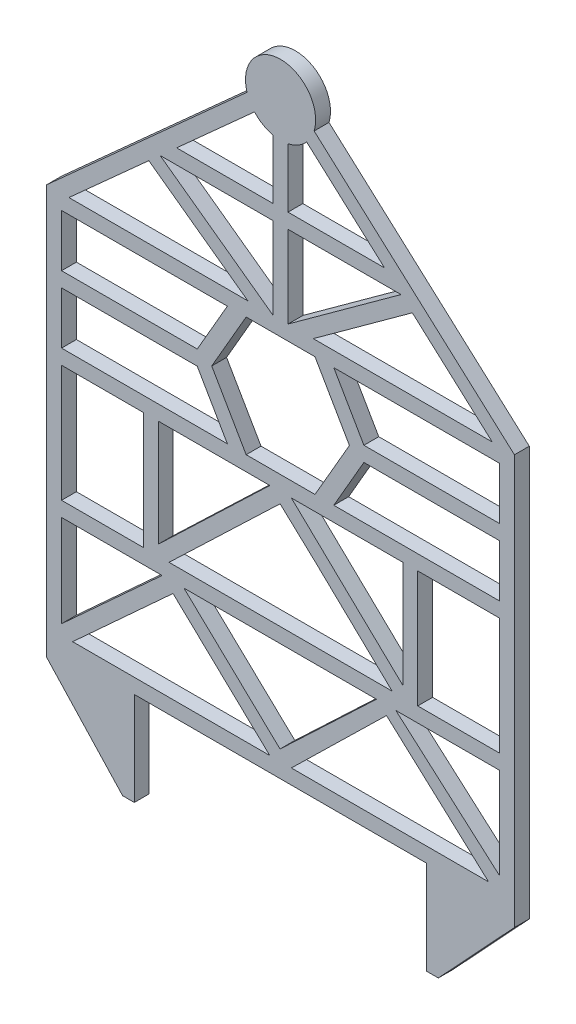
from build123d import *

# Parameters (mm, degrees)
SKETCH2_W           = 70
SKETCH2_H           = 100
BOSS_EXTRUDE3_DEPTH = 12.7


with BuildPart() as part:
    # Sketch2 → Boss-Extrude3 (new body)
    with BuildSketch(Plane.XY):
        with BuildLine():
            Line((-200, -230.044545372), (-135.055496126, -300))
            Line((-135.055496126, -300), (-125.080405008, -300))
            Line((-125.080405008, -300), (-125.080405008, -220))
            Line((-125.080405008, -220), (124.919594992, -220))
            Line((124.919594992, -220), (124.919594992, -300))
            Line((124.919594992, -300), (134.911595754, -300))
            Line((134.911595754, -300), (200, -230.044545372))
            Line((200, -230.044545372), (200, 120.049170717))
            Line((200, 120.049170717), (28.699194546, 274.177780708))
            ThreePointArc((28.699194546, 274.177780708), (0, 312.915986038), (-28.699194546, 274.177780708))
            Line((-28.699194546, 274.177780708), (-200, 120.049170717))
            Line((-200, 120.049170717), (-200, -230.044545372))
        make_face()
        Polygon((-187.3, -198.731620565), (-187.3, -120), (-101.303698117, -120), align=None, mode=Mode.SUBTRACT)
        Polygon((-177.851600054, -207.3), (-91.979918019, -128.682471814), (-9.219885484, -207.3), align=None, mode=Mode.SUBTRACT)
        Polygon((-0.473030641, -198.092257044), (-82.680114516, -120), (82.015084133, -120), align=None, mode=Mode.SUBTRACT)
        with Locations((-152.3, -57.3)):
            Rectangle(SKETCH2_W, SKETCH2_H, mode=Mode.SUBTRACT)
        Polygon((-71.265160823, 50.024585359), (-45.501144454, 5.4), (-187.3, 5.4), (-187.3, 50.024585359), align=None, mode=Mode.SUBTRACT)
        Polygon((-104.6, -7.3), (-9.189123593, -7.3), (-104.6, -98.514987005), align=None, mode=Mode.SUBTRACT)
        Polygon((177.8939034, -207.3), (9.189123593, -207.3), (90.58572411, -127.795746586), (161.581783291, -192.372871222), align=None, mode=Mode.SUBTRACT)
        Polygon((187.3, -198.092257044), (98.567023769, -120), (187.3, -120), align=None, mode=Mode.SUBTRACT)
        Polygon((-95.410876407, -107.3), (-0.412987416, -16.479838441), (30.242078983, -44.997134394), (95.410876407, -107.3), align=None, mode=Mode.SUBTRACT)
        Polygon((9.189123593, -7.3), (104.6, -7.3), (104.6, -98.514987005), align=None, mode=Mode.SUBTRACT)
        with Locations((152.3, -57.3)):
            Rectangle(SKETCH2_W, SKETCH2_H, mode=Mode.SUBTRACT)
        Polygon((-45.501144454, 107.349170717), (-71.265160823, 62.724585359), (-187.3, 62.724585359), (-187.3, 107.349170717), align=None, mode=Mode.SUBTRACT)
        Polygon((-112.679699791, 181.531958935), (-27.970761031, 120.049170717), (-181.012575458, 120.049170717), align=None, mode=Mode.SUBTRACT)
        Polygon((-103.026071592, 190.217850935), (-6.35, 190.217850935), (-6.35, 120.049170717), align=None, mode=Mode.SUBTRACT)
        with BuildLine():
            Line((-6.35, 253.595728536), (-6.35, 202.917850935))
            Line((-6.35, 202.917850935), (-88.911104686, 202.917850935))
            Line((-88.911104686, 202.917850935), (-22.301550494, 262.85007351))
            ThreePointArc((-22.301550494, 262.85007351), (-15.054519642, 256.966777219), (-6.35, 253.595728536))
        make_face(mode=Mode.SUBTRACT)
        Polygon((29.439464567, 5.383936982), (-29.439464567, 5.383936982), (-58.878929133, 56.374585359), (-29.439464567, 107.365233736), (29.439464567, 107.365233736), (58.878929133, 56.374585359), align=None, mode=Mode.SUBTRACT)
        Polygon((187.3, 5.4), (45.501144454, 5.4), (71.265160823, 50.024585359), (187.3, 50.024585359), align=None, mode=Mode.SUBTRACT)
        Polygon((187.3, 107.349170717), (187.3, 62.724585359), (71.265160823, 62.724585359), (45.501144454, 107.349170717), align=None, mode=Mode.SUBTRACT)
        Polygon((6.35, 120.049170717), (6.35, 190.217850935), (103.026071592, 190.217850935), align=None, mode=Mode.SUBTRACT)
        with BuildLine():
            Line((6.35, 202.917850935), (6.35, 253.595728536))
            ThreePointArc((6.35, 253.595728536), (15.054519642, 256.966777219), (22.301550494, 262.85007351))
            Line((22.301550494, 262.85007351), (88.911104686, 202.917850935))
            Line((88.911104686, 202.917850935), (6.35, 202.917850935))
        make_face(mode=Mode.SUBTRACT)
        Polygon((181.012575458, 120.049170717), (27.970761031, 120.049170717), (112.679699791, 181.531958935), align=None, mode=Mode.SUBTRACT)
    extrude(amount=BOSS_EXTRUDE3_DEPTH)


solid = part.part
